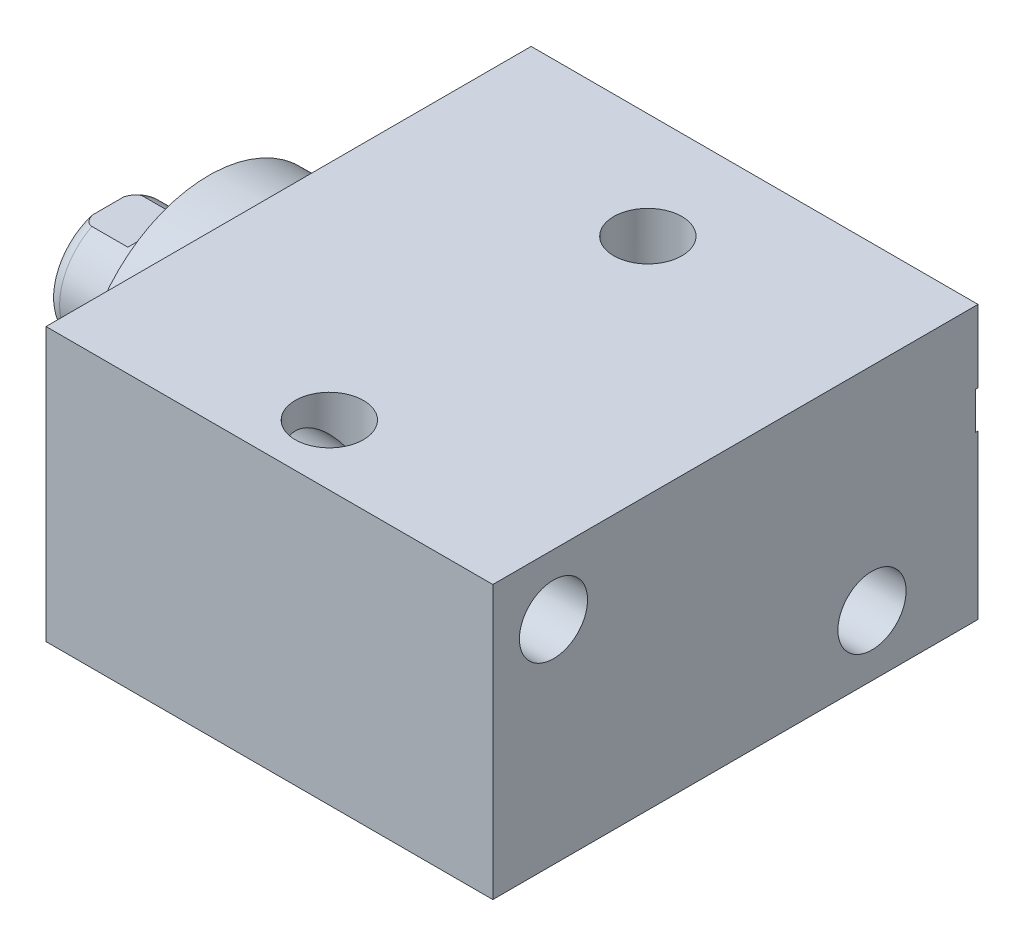
from build123d import *

# Parameters (mm, degrees)
SKETCH1_W          = 50.8
SKETCH1_H          = 28.575
EXTRUDE1_DEPTH     = 46.7868
SKETCH5_R          = 13.5001
EXTRUDE2_DEPTH     = 5.969
SKETCH6_W          = 6.35
SKETCH6_H          = 10.541
CUT_EXTRUDE4_DEPTH = 30.48
HOLE1_D            = 7.1374
HOLE1_DEPTH        = 46.7868
HOLE2_D            = 7.1374
HOLE2_DEPTH        = 28.575


with BuildPart() as part:
    # Sketch1 → Extrude1 (new body)
    with BuildSketch(Plane(origin=(0, 0, 0), x_dir=(0, 0, -1), z_dir=(1, 0, 0))):
        with Locations((2.3876, 0)):
            Rectangle(SKETCH1_W, SKETCH1_H)
    extrude(amount=EXTRUDE1_DEPTH)

    # S2D0002 → Cut-Revolve1 (revolve, cut)
    with BuildSketch(Plane(origin=(0, 4.7625, 0), x_dir=(-1, 0, 0), z_dir=(0, 1, 0)), mode=Mode.PRIVATE) as cut_revolve1_sk:
        Polygon((-15.7099, -27.5336), (-19.0499873, -27.5336), (-19.0499873, -27.7876), (-9.525, -27.7876), (-9.525, -13.5636), (-14.5034, -13.5636), (-14.5034, -24.316993135), (-15.167306865, -24.9809), align=None)
    revolve(cut_revolve1_sk.sketch.rotate(Axis((9.525, 4.7625, -19.13842003), (0, 0, 1)), 180), axis=Axis((9.525, 4.7625, -19.13842003), (0, 0, 1)), mode=Mode.SUBTRACT)  # turned: the seam where the file's is

    # Sketch3 → Cut-Revolve2 (revolve, cut)
    with BuildSketch(Plane(origin=(41.148, 4.7625, -25.146), x_dir=(1, 0, 0), z_dir=(0, 1, 0))):
        Polygon((2.5019, 2.3876), (5.8419873, 2.3876), (5.8419873, 2.6416), (-3.683, 2.6416), (-3.683, -11.5824), (1.2954, -11.5824), (1.2954, -0.829006865), (1.959306865, -0.1651), align=None)
    revolve(axis=Axis((37.465, 4.7625, -3.189624441), (0, 0, -1)), mode=Mode.SUBTRACT)

    # Sketch5 → Extrude2 (add)
    with BuildSketch(Plane.ZY):
        Circle(SKETCH5_R)
    extrude(amount=EXTRUDE2_DEPTH)

    # Sketch6 → Revolve1 (revolve)
    with BuildSketch(Plane(origin=(0, 0, 0), x_dir=(0, 0, 1), z_dir=(0, -1, 0)), mode=Mode.PRIVATE) as revolve1_sk:
        with Locations((-3.175, 11.2395)):
            Rectangle(SKETCH6_W, SKETCH6_H)
    revolve(revolve1_sk.sketch.rotate(Axis((5.754582971, 0, 0), (-1, 0, 0)), 180), axis=Axis((5.754582971, 0, 0), (-1, 0, 0)))  # turned: the seam where the file's is

    # S2D0001 → Cut-Revolve4 (revolve, cut)
    with BuildSketch(Plane(origin=(-18.511260017, 3.2639, 0), x_dir=(0, 1, 0), z_dir=(0, 0, 1)), mode=Mode.PRIVATE) as cut_revolve4_sk:
        Polygon((-0.7112, -3.563050231), (-0.7112, -18.003260017), (-3.2639, -19.53707692), (-3.2639, -2.001260017), (0.1905, -2.001260017), align=None)
    revolve(cut_revolve4_sk.sketch.rotate(Axis((0, 0, 0), (-1, 0, 0)), 90), axis=Axis((0, 0, 0), (-1, 0, 0)), mode=Mode.SUBTRACT)  # turned: the seam where the file's is

    # Sketch8 → Cut-Revolve5 (revolve, cut)
    with BuildSketch(Plane(origin=(0, 0, 0), x_dir=(0, 0, -1), z_dir=(0, 1, 0)), mode=Mode.PRIVATE) as cut_revolve5_sk:
        with BuildLine():
            Line((-6.35, 10.1854), (-6.096, 10.9474))
            Line((-6.096, 10.9474), (-6.096, 15.494))
            ThreePointArc((-6.096, 15.494), (-5.995678675, 16.037796865), (-5.707922533, 16.51))
            Line((-5.707922533, 16.51), (-6.35, 16.51))
            Line((-6.35, 16.51), (-6.35, 10.1854))
        make_face()
    revolve(cut_revolve5_sk.sketch.rotate(Axis((-12.65936, 0, 0), (-1, 0, 0)), 180), axis=Axis((-12.65936, 0, 0), (-1, 0, 0)), mode=Mode.SUBTRACT)  # turned: the seam where the file's is

    # Sketch12 → Cut-Extrude4 (cut, symmetric)
    with BuildSketch(Plane(origin=(0, 0, 0), x_dir=(0, -1, 0), z_dir=(0, 0, -1))):
        Polygon((5.461, 16.51), (5.461, 11.7348), (6.096, 11.0998), (6.096, 16.51), align=None)
        Polygon((-5.461, 16.51), (-5.461, 11.7348), (-6.096, 11.0998), (-6.096, 16.51), align=None)
    extrude(amount=CUT_EXTRUDE4_DEPTH, both=True, mode=Mode.SUBTRACT)

    # Hole1
    with Locations(Plane.ZY):
        with Locations((-16.6878, -7.9248), (16.6624, 7.9502)):
            Hole(HOLE1_D / 2, depth=HOLE1_DEPTH)

    # Hole2
    with Locations(Plane(origin=(0, 14.2875, 0), x_dir=(-1, 0, 0), z_dir=(0, 1, 0))):
        with Locations((-23.3172, -16.6878), (-23.3172, 16.6624)):
            Hole(HOLE2_D / 2, depth=HOLE2_DEPTH)


solid = part.part
